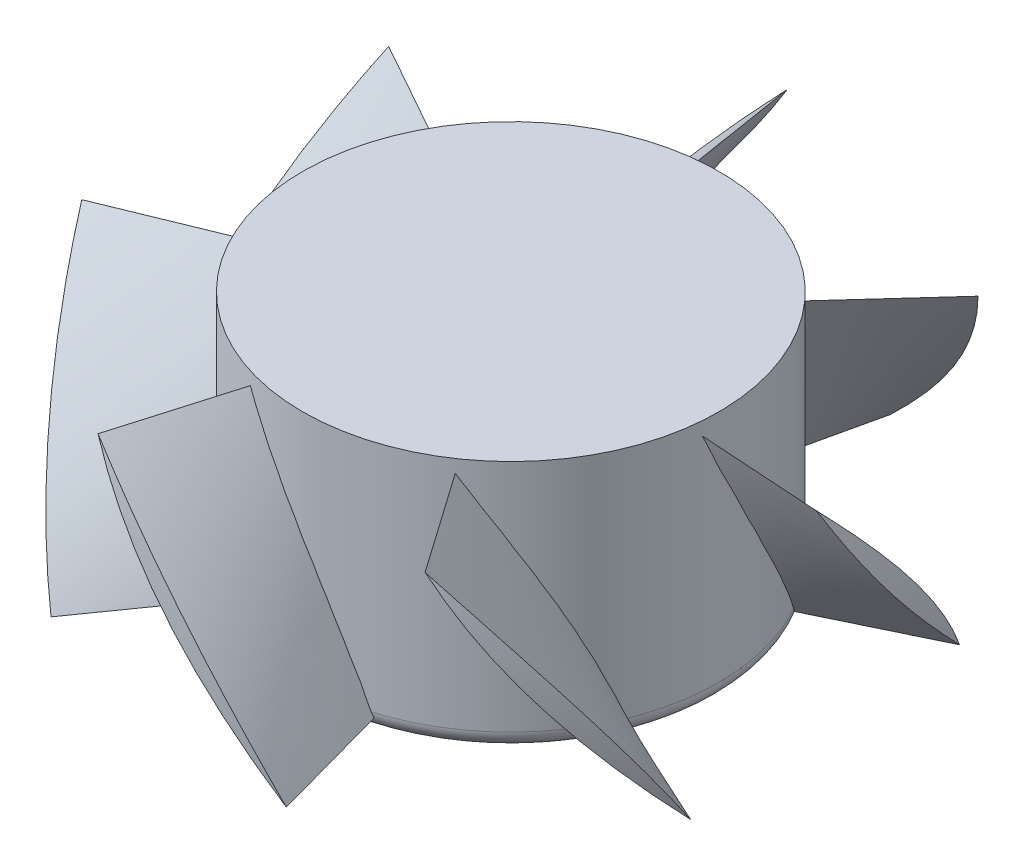
from build123d import *

# Parameters (mm, degrees)
SCHIZZO1_R                        = 17.5
ESTRUSIONE_ESTRUSIONE1_DEPTH      = 9
ESTRUSIONE_ESTRUSIONE1_DEPTH_BACK = 12.2
TAGLIO_ESTRUSIONE2_DEPTH          = 25
RIPETIZIONECIRCOLARE7_COUNT       = 7
RACCORDO1_R                       = 1.5


with BuildPart() as part:
    # Schizzo1 → Estrusione-Estrusione1 (new body, two sides)
    with BuildSketch(Plane(origin=(0, 0, 0), x_dir=(-1, 0, 0), z_dir=(0, 1, 0))) as estrusione_estrusione1_sk:
        Circle(SCHIZZO1_R)
    extrude(amount=ESTRUSIONE_ESTRUSIONE1_DEPTH)
    extrude(estrusione_estrusione1_sk.sketch, amount=-ESTRUSIONE_ESTRUSIONE1_DEPTH_BACK)

    # Raccordo1
    raccordo1_edges = [part.edges().sort_by_distance(p)[0] for p in [
        (17.5, -12.2, 0),
    ]]
    fillet(raccordo1_edges, radius=RACCORDO1_R)


with BuildPart() as body_2:
    # Schizzo5 → Loft1 section 0
    with BuildSketch(Plane.XY.offset(29)):
        with BuildLine():
            add(Edge.make_bspline(
                [(-8.837174774, 7.876988884), (0.685799365, -0.944345589), (8.372212253, -11.393982528)],
                knots=[0, 0, 0, 1, 1, 1], degree=2))
            add(Edge.make_bspline(
                [(-8.837174774, 7.876988884), (-1.725418533, -3.069366959), (8.372212253, -11.393982528)],
                knots=[0, 0, 0, 1, 1, 1], degree=2))
        make_face()
    # Schizzo4 → Loft1 section 1
    with BuildSketch(Plane.XY.offset(16)):
        with BuildLine():
            add(Edge.make_bspline(
                [(-5, 7.9), (-0.519489973, -1.87234341), (5, -11.1)],
                knots=[0, 0, 0, 1, 1, 1], degree=2))
            add(Edge.make_bspline(
                [(-5, 7.9), (1.335439673, -0.881249612), (5, -11.1)],
                knots=[0, 0, 0, 1, 1, 1], degree=2))
        make_face()
    loft()

    # Schizzo9 → Taglio-Estrusione2 (cut)
    with BuildSketch(Plane(origin=(12, 0, 0), x_dir=(0, 0, -1), z_dir=(1, 0, 0))):
        with BuildLine():
            Line((-29.114875703, 9.137740098), (-26.314875703, 9.137740098))
            ThreePointArc((-26.314875703, 9.137740098), (-27.527453372, -1.862259902), (-26.314875703, -12.862259902))
            Line((-26.314875703, -12.862259902), (-29.114875703, -12.862259902))
            Line((-29.114875703, -12.862259902), (-29.114875703, 9.137740098))
        make_face()
    extrude(amount=-TAGLIO_ESTRUSIONE2_DEPTH, mode=Mode.SUBTRACT)


with BuildPart() as ripetizionecircolare7_1:
    # RipetizioneCircolare7: pattern copy
    add(body_2.part.rotate(Axis((0, 9, 0), (0, 1, 0)), 1 * 360 / RIPETIZIONECIRCOLARE7_COUNT))


with BuildPart() as ripetizionecircolare7_2:
    # RipetizioneCircolare7: pattern copy
    add(body_2.part.rotate(Axis((0, 9, 0), (0, 1, 0)), 2 * 360 / RIPETIZIONECIRCOLARE7_COUNT))


with BuildPart() as ripetizionecircolare7_3:
    # RipetizioneCircolare7: pattern copy
    add(body_2.part.rotate(Axis((0, 9, 0), (0, 1, 0)), 3 * 360 / RIPETIZIONECIRCOLARE7_COUNT))


with BuildPart() as ripetizionecircolare7_4:
    # RipetizioneCircolare7: pattern copy
    add(body_2.part.rotate(Axis((0, 9, 0), (0, 1, 0)), 4 * 360 / RIPETIZIONECIRCOLARE7_COUNT))


with BuildPart() as ripetizionecircolare7_5:
    # RipetizioneCircolare7: pattern copy
    add(body_2.part.rotate(Axis((0, 9, 0), (0, 1, 0)), 5 * 360 / RIPETIZIONECIRCOLARE7_COUNT))


with BuildPart() as ripetizionecircolare7_6:
    # RipetizioneCircolare7: pattern copy
    add(body_2.part.rotate(Axis((0, 9, 0), (0, 1, 0)), 6 * 360 / RIPETIZIONECIRCOLARE7_COUNT))


solid = Compound([part.part, body_2.part, ripetizionecircolare7_1.part, ripetizionecircolare7_2.part, ripetizionecircolare7_3.part, ripetizionecircolare7_4.part, ripetizionecircolare7_5.part, ripetizionecircolare7_6.part])
